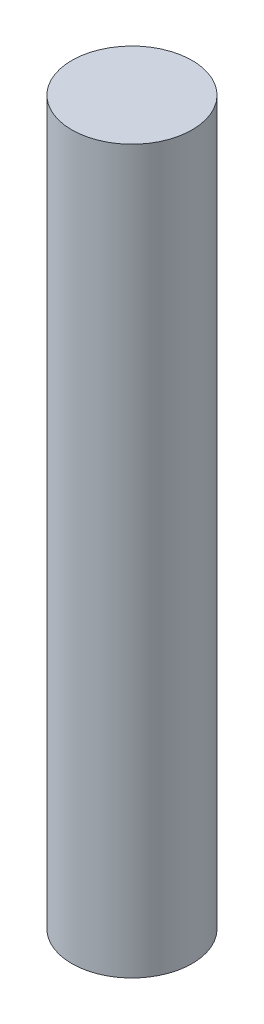
from build123d import *

# Parameters (mm, degrees)
SKETCH1_R           = 12.5
BOSS_EXTRUDE1_DEPTH = 150


with BuildPart() as part:
    # Sketch1 → Boss-Extrude1 (new body)
    with BuildSketch(Plane(origin=(0, 0, 0), x_dir=(1, 0, 0), z_dir=(0, 1, 0))):
        Circle(SKETCH1_R)
    extrude(amount=BOSS_EXTRUDE1_DEPTH)


solid = part.part
